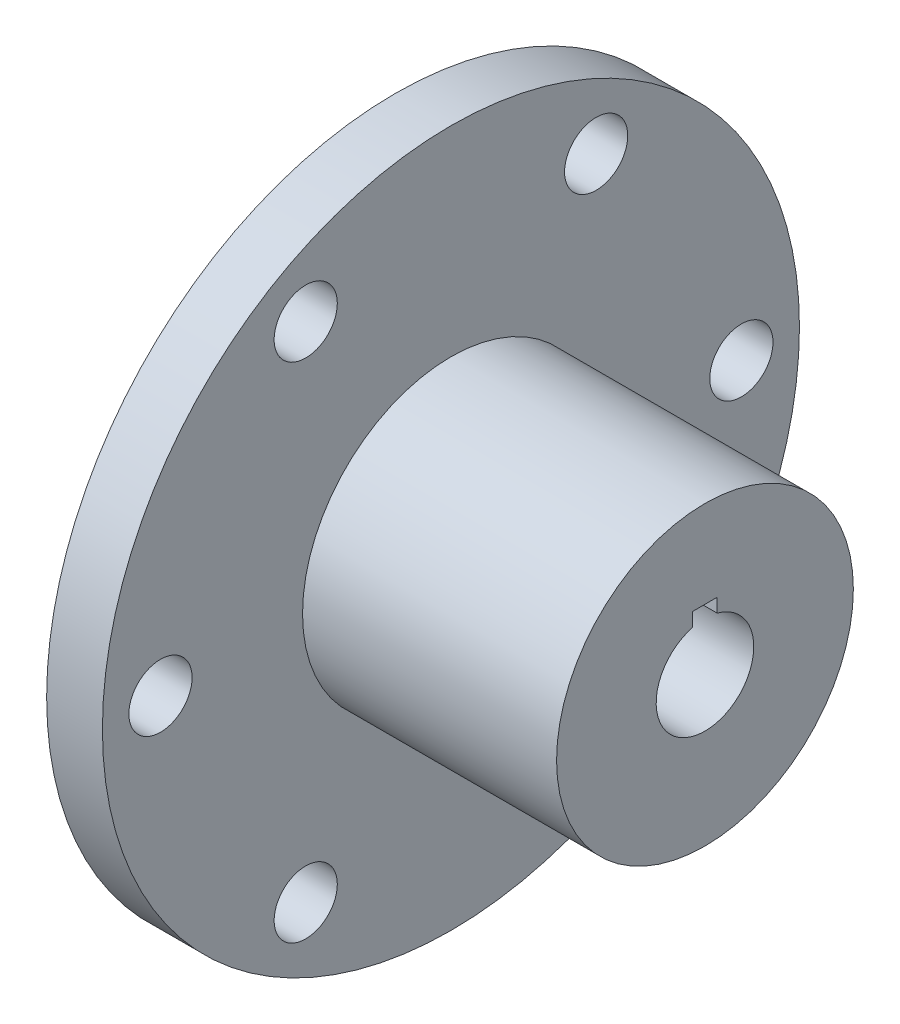
from build123d import *

# Parameters (mm, degrees)
SKETCH1_W           = 4.572
SKETCH1_H           = 28.575
SKETCH2_R           = 12.1666
BOSS_EXTRUDE1_DEPTH = 20.828
CUT_EXTRUDE1_DEPTH  = 26.4
SKETCH4_W           = 25.4
SKETCH4_H           = 4.0005
HOLE1_D             = 5.1816
HOLE1_DEPTH         = 25.4


with BuildPart() as part:
    # Sketch1 → Revolve1 (revolve)
    with BuildSketch(Plane.XY):
        with Locations((-15.321066246, 14.2875)):
            Rectangle(SKETCH1_W, SKETCH1_H)
    revolve(axis=Axis((-17.607066246, 0, 0), (1, 0, 0)))

    # Sketch2 → Boss-Extrude1 (add)
    with BuildSketch(Plane(origin=(-13.035066246, 0, 0), x_dir=(0, 0, -1), z_dir=(1, 0, 0))):
        Circle(SKETCH2_R)
    extrude(amount=BOSS_EXTRUDE1_DEPTH)

    # Sketch3 → Cut-Extrude1 (cut, through all)
    with BuildSketch(Plane.ZY.offset(17.607066246)):
        with BuildLine():
            Line((1.0033, 3.872646299), (1.0033, 5.0038))
            Line((1.0033, 5.0038), (-1.0033, 5.0038))
            Line((-1.0033, 5.0038), (-1.0033, 3.872646299))
            ThreePointArc((-1.0033, 3.872646299), (0, 4.0005), (1.0033, 3.872646299))
        make_face()
    extrude(amount=-CUT_EXTRUDE1_DEPTH, mode=Mode.SUBTRACT)

    # Sketch4 → Cut-Revolve1 (revolve, cut)
    with BuildSketch(Plane(origin=(0, 0, 0), x_dir=(-1, 0, 0), z_dir=(0, 0, -1))):
        with Locations((4.907066246, 2.00025)):
            Rectangle(SKETCH4_W, SKETCH4_H)
    revolve(axis=Axis((7.792933754, 0, 0), (-1, 0, 0)), mode=Mode.SUBTRACT)

    # Hole1
    with Locations(Plane.ZY.offset(17.607066246)):
        with Locations((23.8125, 0), (11.90625, 20.622229928), (-11.90625, 20.622229928), (-23.8125, 0), (-11.90625, -20.622229928), (11.90625, -20.622229928)):
            Hole(HOLE1_D / 2, depth=HOLE1_DEPTH)


solid = part.part
